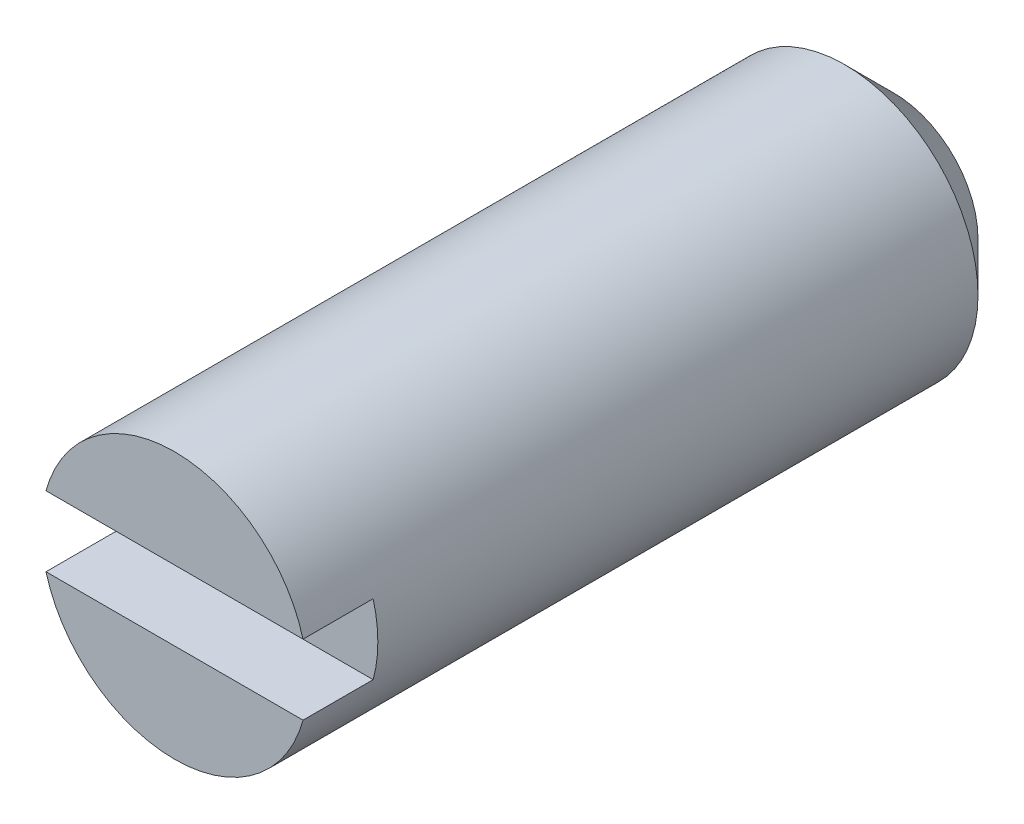
from build123d import *

# Parameters (mm, degrees)
SKETCH1_R          = 2.413
EXTRUDE1_DEPTH     = 13.0302
CHAMFER1_SIZE      = 0.889
SKETCH3_W          = 4.826
SKETCH3_H          = 1.27
CUT_EXTRUDE1_DEPTH = 1.27


with BuildPart() as part:
    # Sketch1 → Extrude1 (new body)
    with BuildSketch(Plane.XY):
        with Locations((6.35, 0)):
            Circle(SKETCH1_R)
    extrude(amount=EXTRUDE1_DEPTH)

    # Chamfer1
    chamfer1_edges = [part.edges().sort_by_distance(p)[0] for p in [
        (3.937, 0, 0),
    ]]
    chamfer(chamfer1_edges, length=CHAMFER1_SIZE)

    # Sketch3 → Cut-Extrude1 (cut)
    with BuildSketch(Plane.XY.offset(13.0302)):
        with Locations((6.35, 0)):
            Rectangle(SKETCH3_W, SKETCH3_H)
    extrude(amount=-CUT_EXTRUDE1_DEPTH, mode=Mode.SUBTRACT)

    # Sketch4 → Revolve3 (revolve)
    with BuildSketch(Plane(origin=(0, 0, 0), x_dir=(1, 0, 0), z_dir=(0, 1, 0))):
        with BuildLine():
            Line((6.35, 0.635), (6.35, -1.7526))
            ThreePointArc((6.35, -1.7526), (5.1562, -0.5588), (6.35, 0.635))
        make_face()
    revolve(axis=Axis((6.35, 0, -0.635), (0, 0, 1)))


solid = part.part
